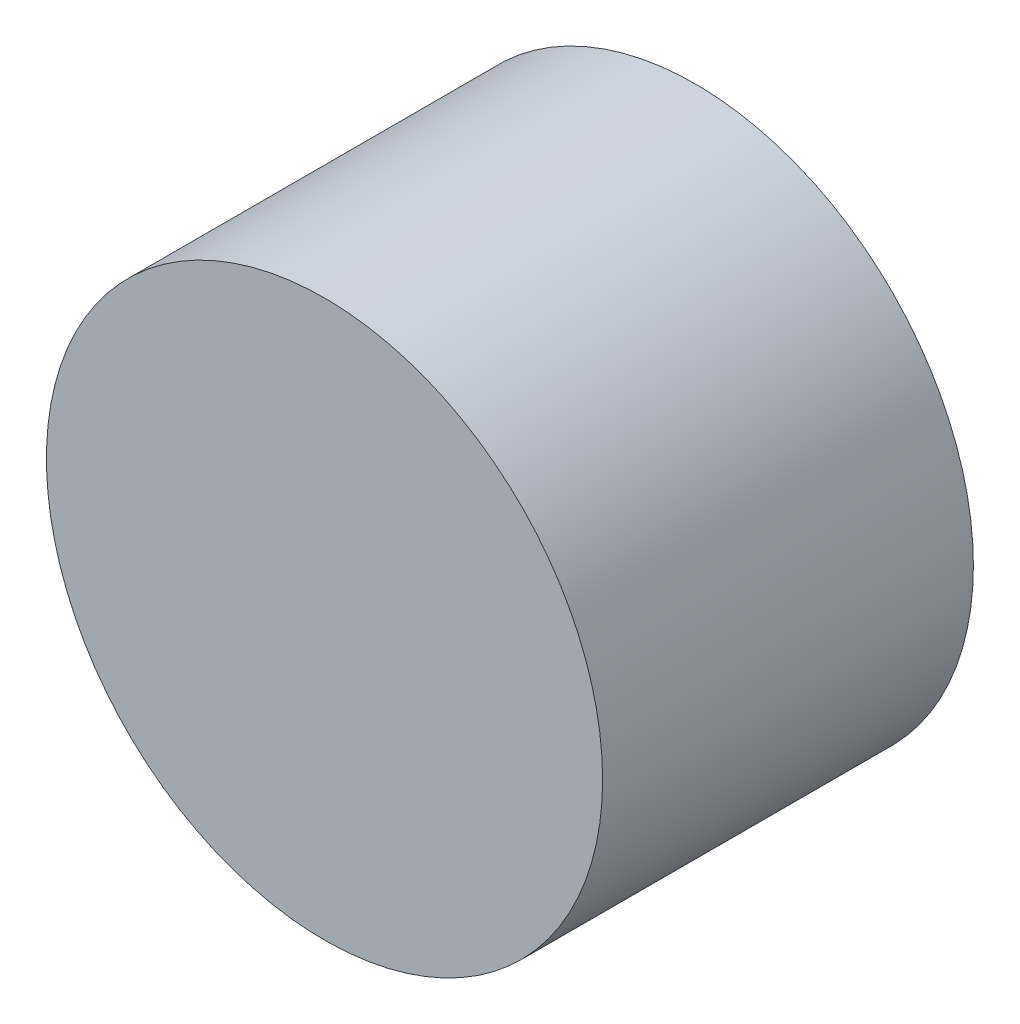
from build123d import *

# Parameters (mm, degrees)
SKETCH1_R           = 7.5
BOSS_EXTRUDE1_DEPTH = 10
SKETCH1_3_R         = 6.25
CUT_EXTRUDE1_DEPTH  = 8


with BuildPart() as part:
    # Sketch1 → Boss-Extrude1 (new body)
    with BuildSketch(Plane.XY):
        Circle(SKETCH1_R)
    extrude(amount=BOSS_EXTRUDE1_DEPTH)

    # Sketch1_3 → Cut-Extrude1 (cut)
    with BuildSketch(Plane.XY):
        Circle(SKETCH1_3_R)
    extrude(amount=CUT_EXTRUDE1_DEPTH, mode=Mode.SUBTRACT)


solid = part.part
